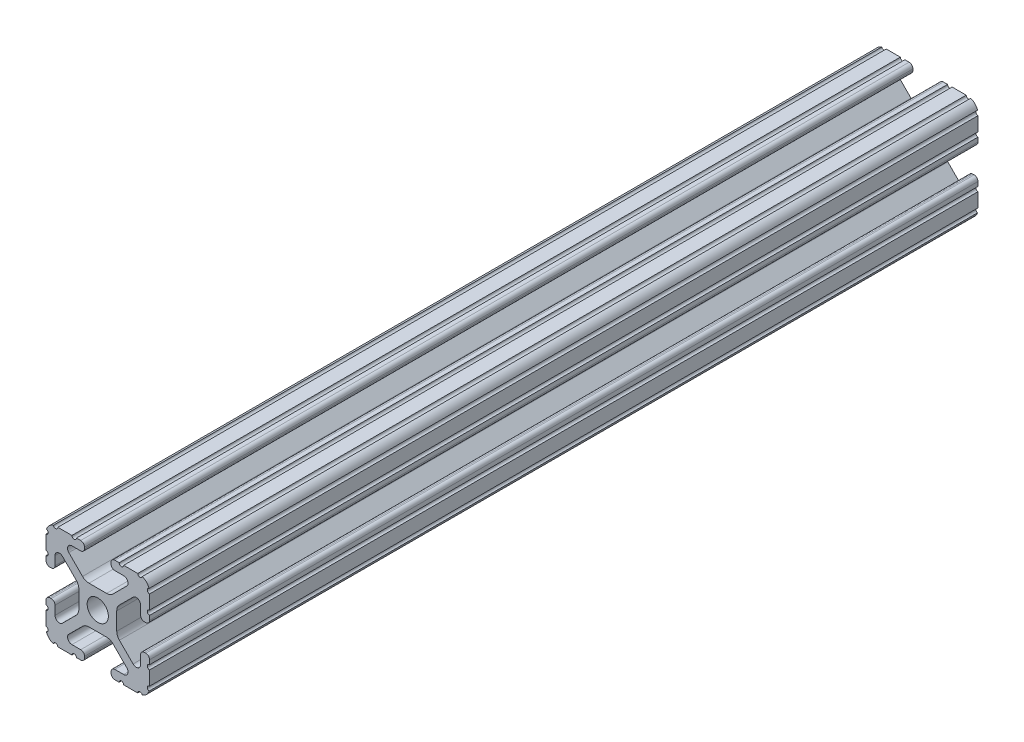
from build123d import *

# Parameters (mm, degrees)
BOSS_EXTRUDE1_DEPTH     = 101.6
SKETCH5_R               = 0.55245
CUT_EXTRUDE1_DEPTH      = 102.6
CUT_EXTRUDE1_DEPTH_BACK = 102.6


with BuildPart() as part:
    # Sketch4 → Boss-Extrude1 (new body, symmetric)
    with BuildSketch(Plane.XY):
        with BuildLine():
            Line((4.190365, -12.7), (10.11729625, -12.7))
            ThreePointArc((10.11729625, -12.7), (11.943543585, -11.943543585), (12.7, -10.11729625))
            Line((12.7, -10.11729625), (12.7, -4.190365))
            ThreePointArc((12.7, -4.190365), (12.42492494, -3.52627506), (11.760835, -3.2512))
            Line((11.760835, -3.2512), (11.429365, -3.2512))
            ThreePointArc((11.429365, -3.2512), (10.76527506, -3.52627506), (10.4902, -4.190365))
            Line((10.4902, -4.190365), (10.4902, -6.348478019))
            ThreePointArc((10.4902, -6.348478019), (9.830707141, -7.335478831), (8.666460301, -7.103895736))
            Line((8.666460301, -7.103895736), (5.299899128, -3.737334563))
            ThreePointArc((5.299899128, -3.737334563), (4.817571085, -3.015479634), (4.6482, -2.16399369))
            Line((4.6482, -2.16399369), (4.6482, 0))
            Line((4.6482, 0), (2.6035, 0))
            ThreePointArc((2.6035, 0), (1.840952505, -1.840952505), (0, -2.6035))
            Line((0, -2.6035), (0, -4.6482))
            Line((0, -4.6482), (2.16399369, -4.6482))
            ThreePointArc((2.16399369, -4.6482), (3.015479634, -4.817571085), (3.737334563, -5.299899128))
            Line((3.737334563, -5.299899128), (7.103895736, -8.666460301))
            ThreePointArc((7.103895736, -8.666460301), (7.335478831, -9.830707141), (6.348478019, -10.4902))
            Line((6.348478019, -10.4902), (4.190365, -10.4902))
            ThreePointArc((4.190365, -10.4902), (3.52627506, -10.76527506), (3.2512, -11.429365))
            Line((3.2512, -11.429365), (3.2512, -11.760835))
            ThreePointArc((3.2512, -11.760835), (3.52627506, -12.42492494), (4.190365, -12.7))
        make_face()
    extrude(amount=BOSS_EXTRUDE1_DEPTH, both=True)

    # Sketch5 → Cut-Extrude1 (cut, two sides)
    with BuildSketch(Plane.XY) as cut_extrude1_sk:
        with Locations((10.356153152, -12.7)):
            Circle(SKETCH5_R)
        with Locations((5.796028019, -12.7)):
            Circle(SKETCH5_R)
        with Locations((12.7, -10.356153152)):
            Circle(SKETCH5_R)
        with Locations((12.7, -5.796028019)):
            Circle(SKETCH5_R)
    extrude(amount=CUT_EXTRUDE1_DEPTH, mode=Mode.SUBTRACT)
    extrude(cut_extrude1_sk.sketch, amount=-CUT_EXTRUDE1_DEPTH_BACK, mode=Mode.SUBTRACT)

    # Mirror1: part across plane


with BuildPart() as part_1:
    add(part.part)
    add(part.part.mirror(Plane(origin=(0, 0, 0), x_dir=(0, 0, 1), z_dir=(1, 0, 0))))

    # Mirror2: part across plane


with BuildPart() as part_2:
    add(part_1.part)
    add(part_1.part.mirror(Plane.ZX))


solid = part_2.part
